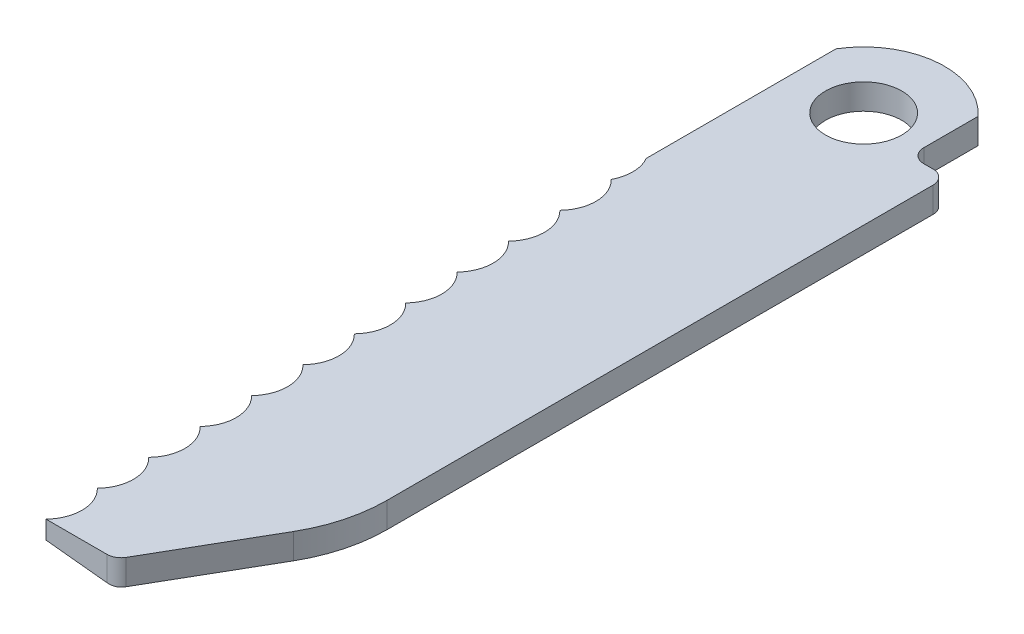
from build123d import *

# Parameters (mm, degrees)
SKETCH1_R           = 2.0955
BOSS_EXTRUDE1_DEPTH = 1.397
CUT_EXTRUDE1_DEPTH  = 52.451
FILLET1_R           = 0.762


with BuildPart() as part:
    # Sketch1 → Boss-Extrude1 (new body)
    with BuildSketch(Plane(origin=(0, 0, 0), x_dir=(1, 0, 0), z_dir=(0, 1, 0))):
        with BuildLine():
            Line((58.251832272, 62.407600024), (58.251832272, 58.66827713))
            Line((58.251832272, 58.66827713), (60.283832272, 58.66827713))
            Line((60.283832272, 58.66827713), (60.283832272, 27.93427713))
            ThreePointArc((60.283832272, 27.93427713), (60.006877388, 25.830595931), (59.194886754, 23.87027713))
            Line((59.194886754, 23.87027713), (55.613371084, 17.666910021))
            Line((55.613371084, 17.666910021), (51.815116638, 17.666910021))
            ThreePointArc((51.815116638, 17.666910021), (52.382112404, 19.118650157), (51.757304959, 20.546462917))
            ThreePointArc((51.757304959, 20.546462917), (52.324300725, 21.998203054), (51.69949328, 23.426015814))
            ThreePointArc((51.69949328, 23.426015814), (52.266489046, 24.87775595), (51.641681601, 26.305568711))
            ThreePointArc((51.641681601, 26.305568711), (52.208677367, 27.757308847), (51.583869921, 29.185121607))
            ThreePointArc((51.583869921, 29.185121607), (52.150865688, 30.636861744), (51.526058242, 32.064674504))
            ThreePointArc((51.526058242, 32.064674504), (52.093054008, 33.51641464), (51.468246563, 34.944227401))
            ThreePointArc((51.468246563, 34.944227401), (52.035242329, 36.395967537), (51.410434884, 37.823780298))
            ThreePointArc((51.410434884, 37.823780298), (51.97743065, 39.275520434), (51.352623205, 40.703333194))
            ThreePointArc((51.352623205, 40.703333194), (51.919618971, 42.155073331), (51.294811526, 43.582886091))
            ThreePointArc((51.294811526, 43.582886091), (51.861807292, 45.034626227), (51.236999847, 46.462438988))
            ThreePointArc((51.236999847, 46.462438988), (51.803995613, 47.914179124), (51.179188167, 49.341991884))
            ThreePointArc((51.179188167, 49.341991884), (51.410778499, 50.327179124), (51.139832272, 51.30227713))
            Line((51.139832272, 51.30227713), (51.139832272, 61.721904416))
            ThreePointArc((51.139832272, 61.721904416), (54.523146654, 63.855838676), (58.251832272, 62.407600024))
        make_face()
        with Locations((54.949832272, 59.43027713)):
            Circle(SKETCH1_R, mode=Mode.SUBTRACT)
    extrude(amount=BOSS_EXTRUDE1_DEPTH)

    # Sketch2 → Cut-Extrude1 (cut)
    with BuildSketch(Plane.XY):
        Polygon((55.613371084, 0), (51.139832272, 0.470187876), (51.139832272, 0), align=None)
    extrude(amount=-CUT_EXTRUDE1_DEPTH, mode=Mode.SUBTRACT)

    # Fillet1
    fillet1_edges = [part.edges().sort_by_distance(p)[0] for p in [
        (58.251832272, 0.6985, -58.66827713),
        (60.283832272, 0.6985, -58.66827713),
        (55.613371084, 0.6985, -17.666910021),
    ]]
    fillet(fillet1_edges, radius=FILLET1_R)


solid = part.part
